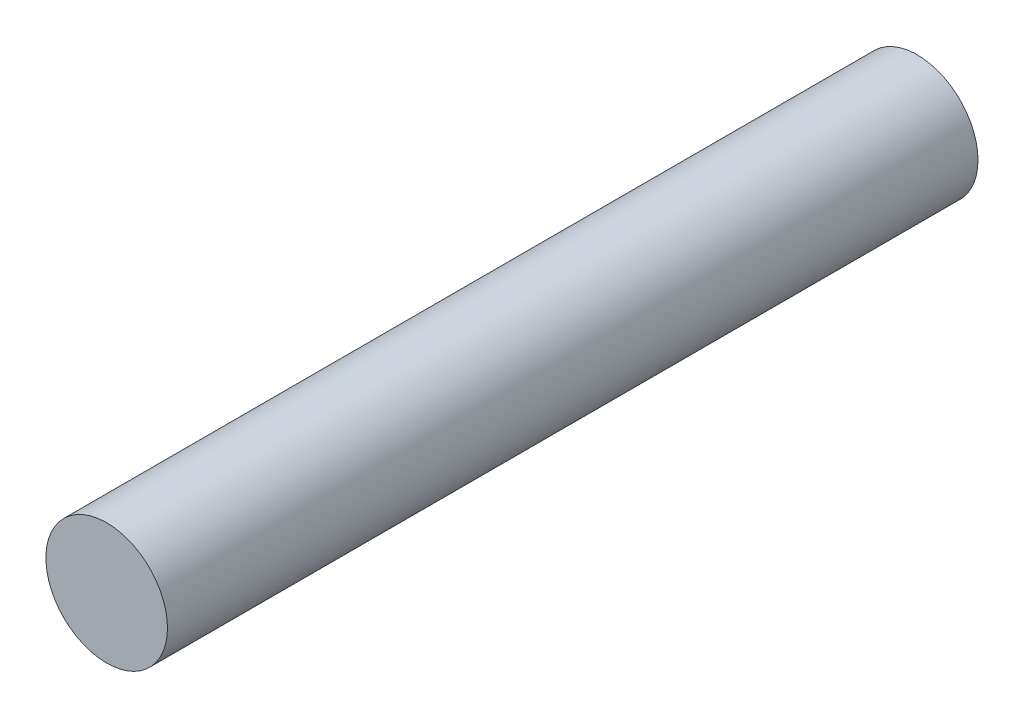
from build123d import *

# Parameters (mm, degrees)
BOSS_EXTRUDE1_DEPTH      = 20
BOSS_EXTRUDE1_DEPTH_BACK = 20
SKETCH1_R                = 3


with BuildPart() as part:
    # Sketch1 → Boss-Extrude1 (new, two sides: drawn at the far end of the back side and taken through both)
    with BuildSketch(Plane.XY.offset(-BOSS_EXTRUDE1_DEPTH_BACK)):
        Circle(SKETCH1_R)
    extrude(amount=BOSS_EXTRUDE1_DEPTH + BOSS_EXTRUDE1_DEPTH_BACK)


solid = part.part
